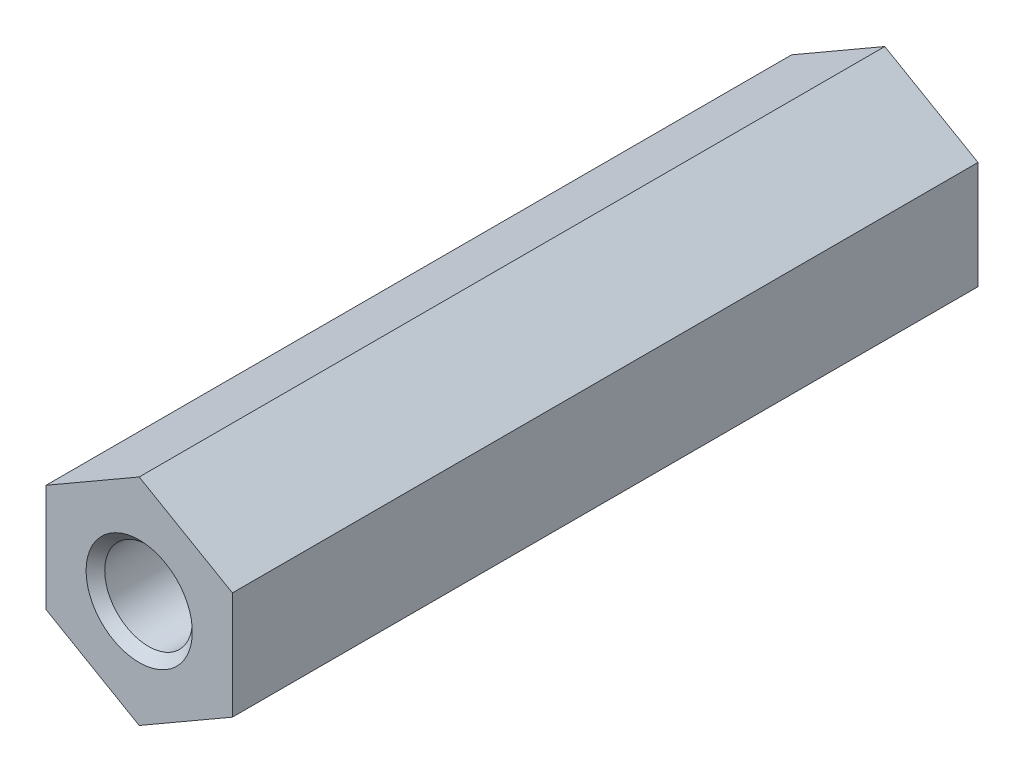
from build123d import *

# Parameters (mm, degrees)
SKETCH1_R           = 2.35
BOSS_EXTRUDE1_DEPTH = 40
CHAMFER4_SIZE       = 0.5


with BuildPart() as part:
    # Sketch1 → Boss-Extrude1 (new body)
    with BuildSketch(Plane(origin=(0, 0, 0), x_dir=(-1, 0, 0), z_dir=(0, 0, -1))):
        Polygon((-5.000000075, 2.886751389), (-5.000000075, -2.886751389), (0, -5.773502778), (5.000000075, -2.886751389), (5.000000075, 2.886751389), (0, 5.773502778), align=None)
        Circle(SKETCH1_R, mode=Mode.SUBTRACT)
    extrude(amount=-BOSS_EXTRUDE1_DEPTH)

    # Chamfer4
    chamfer4_edges = [part.edges().sort_by_distance(p)[0] for p in [
        (2.35, 0, 40),
        (2.35, 0, 0),
    ]]
    chamfer(chamfer4_edges, length=CHAMFER4_SIZE)


solid = part.part
